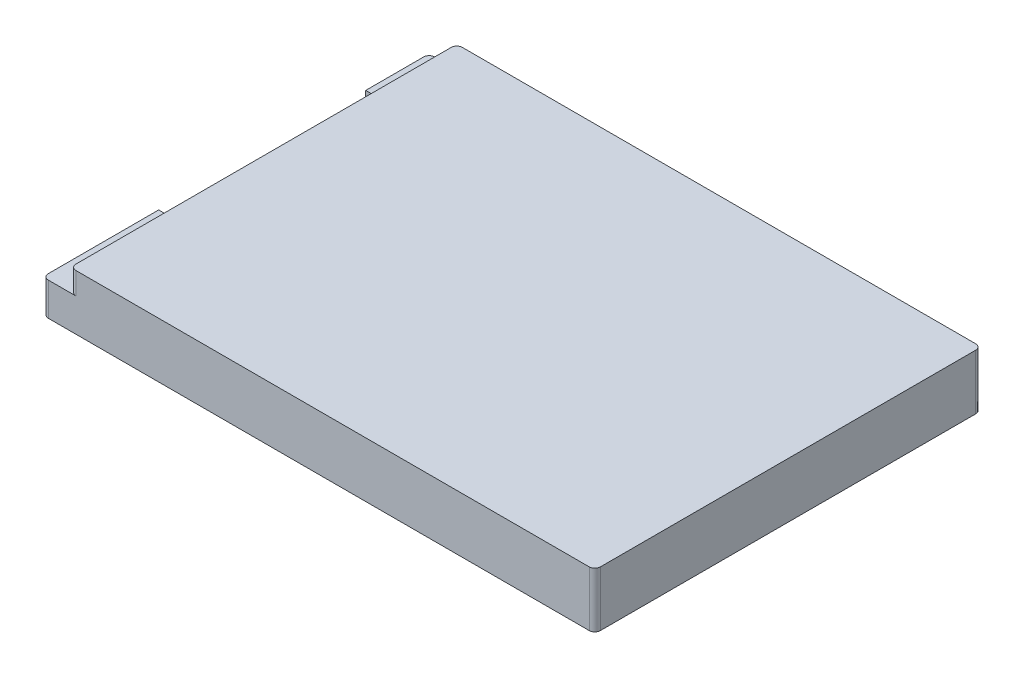
from build123d import *

# Parameters (mm, degrees)
SKETCH1_W           = 100
SKETCH1_H           = 70
BOSS_EXTRUDE1_DEPTH = 10
SKETCH2_R           = 1.5
CUT_EXTRUDE1_DEPTH  = 5
SKETCH3_W           = 17.581829542
SKETCH3_H           = 1.056152304
SKETCH3_W_2         = 9.008357892
CUT_EXTRUDE2_DEPTH  = 5
FILLET1_R           = 1


with BuildPart() as part:
    # Sketch1 → Boss-Extrude1 (new body)
    with BuildSketch(Plane(origin=(0, 0, 0), x_dir=(1, 0, 0), z_dir=(0, 1, 0))):
        with Locations((50, 35)):
            Rectangle(SKETCH1_W, SKETCH1_H)
    extrude(amount=BOSS_EXTRUDE1_DEPTH)

    # Sketch2 → Cut-Extrude1 (cut)
    with BuildSketch(Plane.XZ):
        with Locations((14, -4)):
            Circle(SKETCH2_R)
        with Locations((14, -66)):
            Circle(SKETCH2_R)
        with Locations((91, -66)):
            Circle(SKETCH2_R)
        with Locations((91, -4)):
            Circle(SKETCH2_R)
    extrude(amount=-CUT_EXTRUDE1_DEPTH, mode=Mode.SUBTRACT)

    # Sketch3 → Cut-Extrude2 (cut)
    with BuildSketch(Plane.ZY):
        Polygon((-70, 6), (-70, 10), (0, 10), (0, 6), (-21, 6), (-21, 0), (-58.5, 0), (-58.5, 6), align=None)
        with Locations((-45.810029471, 3.819594483)):
            Rectangle(SKETCH3_W, SKETCH3_H, mode=Mode.SUBTRACT)
        with Locations((-29.035845809, 3.819594483)):
            Rectangle(SKETCH3_W_2, SKETCH3_H, mode=Mode.SUBTRACT)
    extrude(amount=-CUT_EXTRUDE2_DEPTH, mode=Mode.SUBTRACT)

    # Fillet1
    fillet1_edges = [part.edges().sort_by_distance(p)[0] for p in [
        (0, 3, -70),
        (0, 3, 0),
        (5, 8, -70),
        (5, 8, 0),
        (100, 5, -70),
        (100, 5, 0),
    ]]
    fillet(fillet1_edges, radius=FILLET1_R)


solid = part.part
